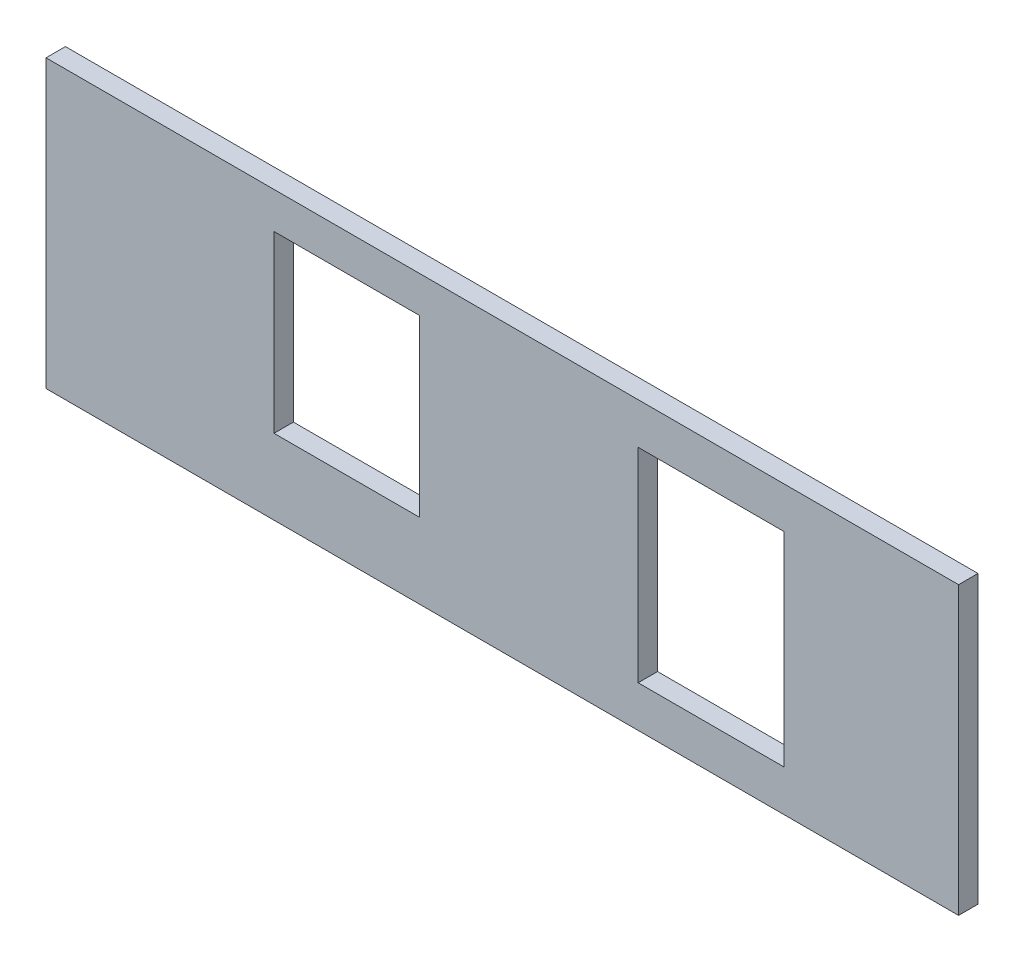
from build123d import *

# Parameters (mm, degrees)
CROQUIS1_W              = 1200
CROQUIS1_H              = 950
SALIENTE_EXTRUIR1_DEPTH = 20
CROQUIS2_W              = 150
CROQUIS2_H              = 180
CORTAR_EXTRUIR1_DEPTH   = 20
CROQUIS3_W              = 650
CROQUIS3_H              = 500
CORTAR_EXTRUIR2_DEPTH   = 20
CORTAR_EXTRUIR4_DEPTH   = 50
CROQUIS7_W              = 150
CROQUIS7_H              = 210
CORTAR_EXTRUIR5_DEPTH   = 50
CROQUIS8_W              = 1514.751276537
CROQUIS8_H              = 489.569354176
CORTAR_EXTRUIR6_DEPTH   = 30
CROQUIS9_W              = 1728.554056326
CROQUIS9_H              = 479.757846805
CORTAR_EXTRUIR7_DEPTH   = 30
CROQUIS10_W             = 90.2
CROQUIS10_H             = 295
CROQUIS10_W_2           = 170
CORTAR_EXTRUIR8_DEPTH   = 30


with BuildPart() as part:
    # Croquis1 → Saliente-Extruir1 (new body)
    with BuildSketch(Plane.XY):
        Rectangle(CROQUIS1_W, CROQUIS1_H)
    extrude(amount=SALIENTE_EXTRUIR1_DEPTH)

    # Croquis2 → Cortar-Extruir1 (cut)
    with BuildSketch(Plane.XY.offset(20)):
        with Locations((-200, 345)):
            Rectangle(CROQUIS2_W, CROQUIS2_H)
    extrude(amount=-CORTAR_EXTRUIR1_DEPTH, mode=Mode.SUBTRACT)

    # Croquis3 → Cortar-Extruir2 (cut)
    with BuildSketch(Plane(origin=(0, 0, 0), x_dir=(-1, 0, 0), z_dir=(0, 0, -1))):
        with Locations((-50, -165)):
            Rectangle(CROQUIS3_W, CROQUIS3_H)
    extrude(amount=-CORTAR_EXTRUIR2_DEPTH, mode=Mode.SUBTRACT)

    # Croquis6 → Cortar-Extruir4 (cut)
    with BuildSketch(Plane(origin=(0, 0, 0), x_dir=(-1, 0, 0), z_dir=(0, 0, -1))):
        Polygon((600, 175), (-600, 175), (-633.284588691, 175), (-633.284588691, -516.156085413), (737.025481355, -516.156085413), (737.025481355, 175), align=None)
    extrude(amount=-CORTAR_EXTRUIR4_DEPTH, mode=Mode.SUBTRACT)

    # Croquis7 → Cortar-Extruir5 (cut)
    with BuildSketch(Plane(origin=(0, 0, 0), x_dir=(-1, 0, 0), z_dir=(0, 0, -1))):
        with Locations((-175, 325)):
            Rectangle(CROQUIS7_W, CROQUIS7_H)
    extrude(amount=-CORTAR_EXTRUIR5_DEPTH, mode=Mode.SUBTRACT)

    # Croquis8 → Cortar-Extruir6 (cut)
    with BuildSketch(Plane(origin=(0, 0, 0), x_dir=(-1, 0, 0), z_dir=(0, 0, -1))):
        with Locations((-63.357770541, 717.284677088)):
            Rectangle(CROQUIS8_W, CROQUIS8_H)
    extrude(amount=-CORTAR_EXTRUIR6_DEPTH, mode=Mode.SUBTRACT)

    # Croquis9 → Cortar-Extruir7 (cut)
    with BuildSketch(Plane(origin=(0, 0, 0), x_dir=(-1, 0, 0), z_dir=(0, 0, -1))):
        with Locations((-91.228936592, -62.378923403)):
            Rectangle(CROQUIS9_W, CROQUIS9_H)
    extrude(amount=-CORTAR_EXTRUIR7_DEPTH, mode=Mode.SUBTRACT)

    # Croquis10 → Cortar-Extruir8 (cut)
    with BuildSketch(Plane(origin=(0, 0, 0), x_dir=(-1, 0, 0), z_dir=(0, 0, -1))):
        with Locations((554.9, 325)):
            Rectangle(CROQUIS10_W, CROQUIS10_H)
        with Locations((-515, 325)):
            Rectangle(CROQUIS10_W_2, CROQUIS10_H)
    extrude(amount=-CORTAR_EXTRUIR8_DEPTH, mode=Mode.SUBTRACT)


solid = part.part
